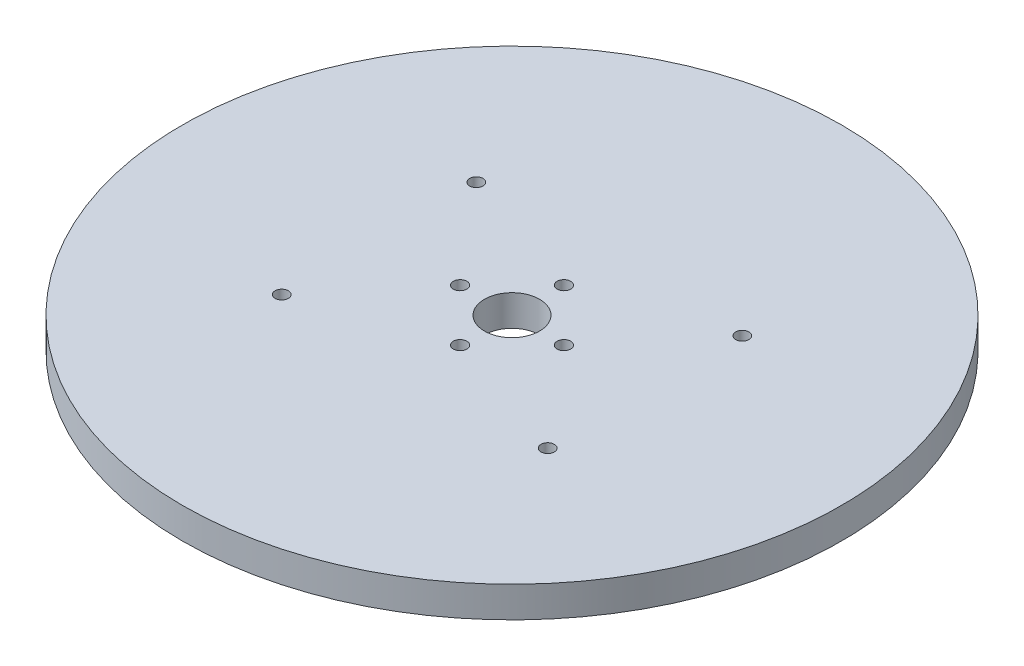
from build123d import *

# Parameters (mm, degrees)
SKETCH1_R           = 50.8
BOSS_EXTRUDE1_DEPTH = 4.7625
SKETCH2_R           = 1.05
CUT_EXTRUDE1_DEPTH  = 5.7625
SKETCH3_R           = 4.25
CUT_EXTRUDE2_DEPTH  = 5.7625
SKETCH4_R           = 1.025
CUT_EXTRUDE3_DEPTH  = 5.7625
SKETCH6_R           = 15
BOSS_EXTRUDE2_DEPTH = 1.5875


with BuildPart() as part:
    # Sketch1 → Boss-Extrude1 (new body)
    with BuildSketch(Plane(origin=(0, 0, 0), x_dir=(1, 0, 0), z_dir=(0, 1, 0))):
        Circle(SKETCH1_R)
    extrude(amount=BOSS_EXTRUDE1_DEPTH)

    # Sketch2 → Cut-Extrude1 (cut, through all)
    with BuildSketch(Plane(origin=(0, 4.7625, 0), x_dir=(-1, 0, 0), z_dir=(0, 1, 0))):
        with Locations((0, 8)):
            Circle(SKETCH2_R)
        with Locations((-8, 0)):
            Circle(SKETCH2_R)
        with Locations((0, -8)):
            Circle(SKETCH2_R)
        with Locations((8, 0)):
            Circle(SKETCH2_R)
    extrude(amount=-CUT_EXTRUDE1_DEPTH, mode=Mode.SUBTRACT)

    # Sketch3 → Cut-Extrude2 (cut, through all)
    with BuildSketch(Plane(origin=(0, 4.7625, 0), x_dir=(-1, 0, 0), z_dir=(0, 1, 0))):
        Circle(SKETCH3_R)
    extrude(amount=-CUT_EXTRUDE2_DEPTH, mode=Mode.SUBTRACT)

    # Sketch4 → Cut-Extrude3 (cut, through all)
    with BuildSketch(Plane(origin=(0, 4.7625, 0), x_dir=(-1, 0, 0), z_dir=(0, 1, 0))):
        with Locations((-20.5, 15)):
            Circle(SKETCH4_R)
        with Locations((20.5, 15)):
            Circle(SKETCH4_R)
        with Locations((20.5, -15)):
            Circle(SKETCH4_R)
        with Locations((-20.5, -15)):
            Circle(SKETCH4_R)
    extrude(amount=-CUT_EXTRUDE3_DEPTH, mode=Mode.SUBTRACT)


with BuildPart() as body_2:
    # Sketch6 → Boss-Extrude2 (new body)
    with BuildSketch(Plane.XZ):
        with BuildLine():
            ThreePointArc((-13.129796139, 16.389278609), (-26.552727442, 19.428824958), (-19.593954345, 7.554929062))
            ThreePointArc((-19.593954345, 7.554929062), (-21, 0), (-19.593954345, -7.554929062))
            ThreePointArc((-19.593954345, -7.554929062), (-26.552727442, -19.428824958), (-13.129796139, -16.389278609))
            ThreePointArc((-13.129796139, -16.389278609), (0, -21), (13.129796139, -16.389278609))
            ThreePointArc((13.129796139, -16.389278609), (26.552727442, -19.428824958), (19.593954345, -7.554929062))
            ThreePointArc((19.593954345, -7.554929062), (21, 0), (19.593954345, 7.554929062))
            ThreePointArc((19.593954345, 7.554929062), (26.552727442, 19.428824958), (13.129796139, 16.389278609))
            ThreePointArc((13.129796139, 16.389278609), (0, 21), (-13.129796139, 16.389278609))
        make_face()
        Circle(SKETCH6_R, mode=Mode.SUBTRACT)
        Polygon((-17.642116168, 15), (-19.071058084, 17.475), (-21.928941916, 17.475), (-23.357883832, 15), (-21.928941916, 12.525), (-19.071058084, 12.525), align=None, mode=Mode.SUBTRACT)
        Polygon((21.928941916, 17.475), (19.071058084, 17.475), (17.642116168, 15), (19.071058084, 12.525), (21.928941916, 12.525), (23.357883832, 15), align=None, mode=Mode.SUBTRACT)
        Polygon((21.928941916, -12.525), (19.071058084, -12.525), (17.642116168, -15), (19.071058084, -17.475), (21.928941916, -17.475), (23.357883832, -15), align=None, mode=Mode.SUBTRACT)
        Polygon((-21.928941916, -12.525), (-23.357883832, -15), (-21.928941916, -17.475), (-19.071058084, -17.475), (-17.642116168, -15), (-19.071058084, -12.525), align=None, mode=Mode.SUBTRACT)
    extrude(amount=BOSS_EXTRUDE2_DEPTH)


solid = Compound([part.part, body_2.part])
